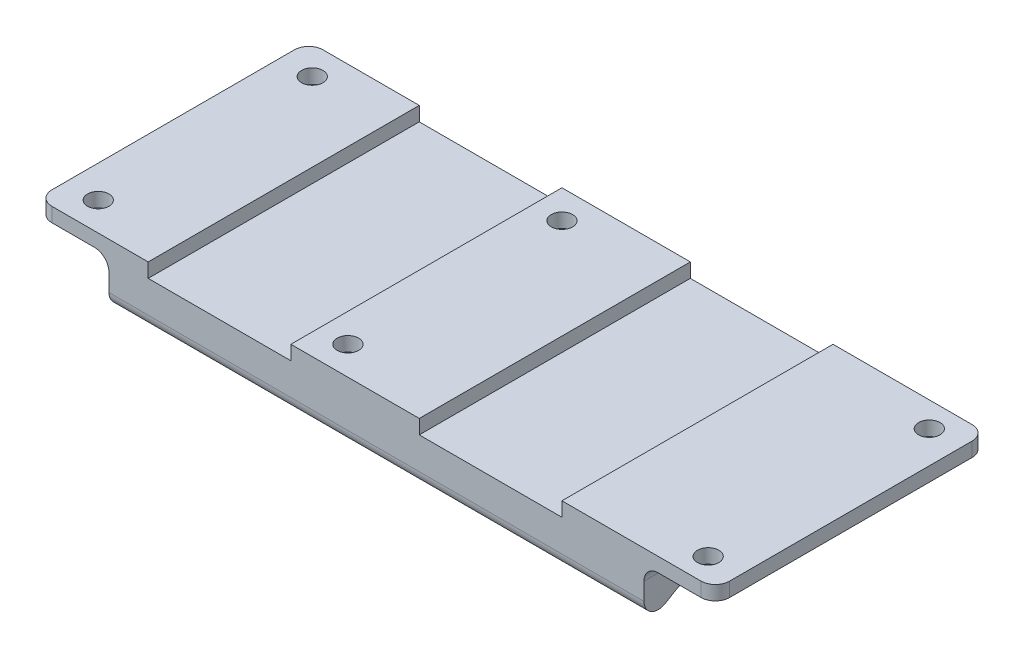
from build123d import *

# Parameters (mm, degrees)
SKETCH1_W               = 75
SKETCH1_H               = 38
BOSS_EXTRUDE1_DEPTH     = 10
CUT_EXTRUDE1_DEPTH      = 1
CUT_EXTRUDE1_DEPTH_BACK = 76
FILLET1_R               = 2
SKETCH4_W               = 38
SKETCH4_H               = 2
BOSS_EXTRUDE2_DEPTH     = 10
SKETCH5_W               = 38
SKETCH5_H               = 2
BOSS_EXTRUDE3_DEPTH     = 10
SKETCH6_R               = 1.5
CUT_EXTRUDE2_DEPTH      = 10
CUT_EXTRUDE3_START      = -2
SKETCH8_R               = 2.75
SKETCH8_R_2             = 1.5
CUT_EXTRUDE3_DEPTH      = 7.467619342
FILLET2_R               = 0.2
CUT_EXTRUDE4_DEPTH      = 39.0000001
FILLET3_R               = 2


with BuildPart() as part:
    # Sketch1 → Boss-Extrude1 (new body)
    with BuildSketch(Plane(origin=(0, 0, 0), x_dir=(1, 0, 0), z_dir=(0, 1, 0))):
        with Locations((8, 0)):
            Rectangle(SKETCH1_W, SKETCH1_H)
    extrude(amount=-BOSS_EXTRUDE1_DEPTH)

    # Sketch2 → Cut-Extrude1 (cut, two sides)
    with BuildSketch(Plane(origin=(45.5, 0, 0), x_dir=(0, 0, -1), z_dir=(1, 0, 0))) as cut_extrude1_sk:
        Polygon((-14, -7), (-19, -10), (0, -10), (0, -7), align=None)
        Polygon((0, -7), (0, -10), (19, -10), (14, -7), align=None)
    extrude(amount=CUT_EXTRUDE1_DEPTH, mode=Mode.SUBTRACT)
    extrude(cut_extrude1_sk.sketch, amount=-CUT_EXTRUDE1_DEPTH_BACK, mode=Mode.SUBTRACT)

    # Fillet1
    fillet1_edges = [part.edges().sort_by_distance(p)[0] for p in [
        (8, -10, -19),
        (8, -7, 14),
        (8, -7, -14),
        (8, -10, 19),
    ]]
    fillet(fillet1_edges, radius=FILLET1_R)

    # Sketch4 → Boss-Extrude2 (add)
    with BuildSketch(Plane.ZY.offset(29.5)):
        with Locations((0, -1)):
            Rectangle(SKETCH4_W, SKETCH4_H)
    extrude(amount=BOSS_EXTRUDE2_DEPTH)

    # Sketch5 → Boss-Extrude3 (add)
    with BuildSketch(Plane(origin=(45.5, 0, 0), x_dir=(0, 0, -1), z_dir=(1, 0, 0))):
        with Locations((0, -1)):
            Rectangle(SKETCH5_W, SKETCH5_H)
    extrude(amount=BOSS_EXTRUDE3_DEPTH)

    # Sketch6 → Cut-Extrude2 (cut)
    with BuildSketch(Plane(origin=(0, 0, 0), x_dir=(1, 0, 0), z_dir=(0, 1, 0))):
        with Locations((51, 15.5)):
            Circle(SKETCH6_R)
        with Locations((-35, 15)):
            Circle(SKETCH6_R)
        with Locations((0, 15)):
            Circle(SKETCH6_R)
        with Locations((-35, -15)):
            Circle(SKETCH6_R)
        with Locations((0, -15)):
            Circle(SKETCH6_R)
        with Locations((51, -15.5)):
            Circle(SKETCH6_R)
    extrude(amount=-CUT_EXTRUDE2_DEPTH, mode=Mode.SUBTRACT)

    # Sketch8 → Cut-Extrude3 (cut, through all)
    with BuildSketch(Plane(origin=(0, 0, 0), x_dir=(1, 0, 0), z_dir=(0, 1, 0)).offset(CUT_EXTRUDE3_START)):
        with Locations((0, -15)):
            Circle(SKETCH8_R)
        with Locations((0, -15)):
            Circle(SKETCH8_R_2, mode=Mode.SUBTRACT)
        with Locations((0, 15)):
            Circle(SKETCH8_R)
        with Locations((0, 15)):
            Circle(SKETCH8_R_2, mode=Mode.SUBTRACT)
    extrude(amount=-CUT_EXTRUDE3_DEPTH, mode=Mode.SUBTRACT)

    # Fillet2
    fillet2_edges = [part.edges().sort_by_distance(p)[0] for p in [
        (8, -6.467619242, -19),
        (0, -7, 12.25),
        (0, -8.321668864, 17.75),
        (-2.740403976, -7.737720648, 15.229534413),
        (2.705728801, -7.894875222, 15.491458704),
        (2.54439776, -7.066285911, 13.956668767),
        (-2.54439776, -7.06628591, 13.956668767),
        (0, -7, -12.25),
        (-2.54439776, -7.066285911, -13.956668767),
        (-2.740403976, -7.737720648, -15.229534413),
        (2.705728801, -7.894875222, -15.491458704),
        (2.54439776, -7.06628591, -13.956668767),
    ]]
    fillet(fillet2_edges, radius=FILLET2_R)

    # Sketch9 → Cut-Extrude4 (cut, through all)
    with BuildSketch(Plane.XY.offset(19)):
        Polygon((-4, -2), (-4, 0), (-14, 0), (-24, 0), (-24, -2), align=None)
        Polygon((24, 0), (14, 0), (14, -2), (34, -2), (34, 0), align=None)
    extrude(amount=-CUT_EXTRUDE4_DEPTH, mode=Mode.SUBTRACT)

    # Fillet3
    fillet3_edges = [part.edges().sort_by_distance(p)[0] for p in [
        (-29.5, -2, 0),
        (-39.5, -1, -19),
        (-39.5, -1, 19),
        (45.5, -2, 0),
        (55.5, -1, 19),
        (55.5, -1, -19),
    ]]
    fillet(fillet3_edges, radius=FILLET3_R)


solid = part.part
